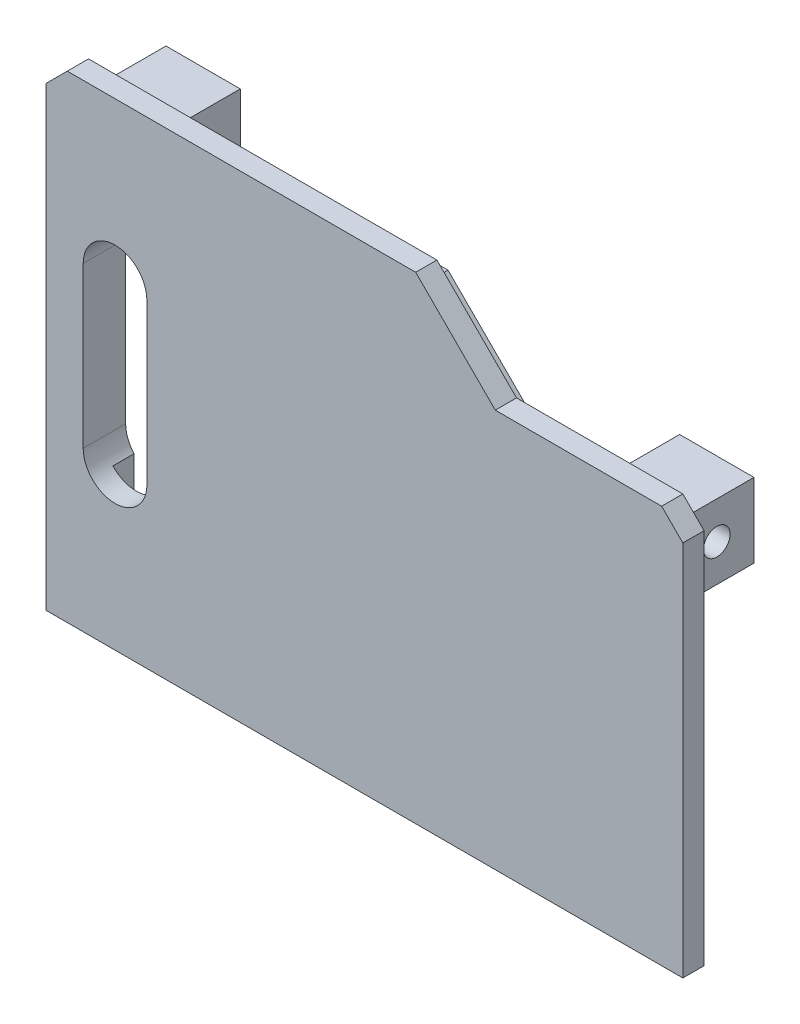
from build123d import *

# Parameters (mm, degrees)
EXTRUDE_1_DEPTH          = 2
EXTRUDE_3_DEPTH          = 2
SKETCH_5_W               = 7
SKETCH_5_H               = 7
SKETCH_5_R               = 1.25
EXTRUDE_4_DEPTH          = 7
SKETCH_6_W               = 7
SKETCH_6_H               = 7
SKETCH_6_R               = 1.25
EXTRUDE_5_DEPTH          = 7
CUT_EXTRUDE_1_DEPTH      = 7
CUT_EXTRUDE_1_DEPTH_BACK = 2


with BuildPart() as part:
    # Эскиз1 → Бобышка-Вытянуть1 (new body)
    with BuildSketch(Plane.XY):
        Polygon((-30, 20.5), (-28, 22.5), (4.828427125, 22.5), (12.328427125, 15), (28, 15), (30, 13), (30, -22.5), (-30, -22.5), align=None)
    extrude(amount=EXTRUDE_1_DEPTH)

    # Эскиз4 → Бобышка-Вытянуть3 (add)
    with BuildSketch(Plane(origin=(0, 0, 0), x_dir=(-1, 0, 0), z_dir=(0, 0, -1))):
        Polygon((-27.7, -20.2), (-27.7, 12.7), (-11.375735931, 12.7), (-3.875735931, 20.2), (27.7, 20.2), (27.7, -20.2), align=None)
        Polygon((-25.7, 10.7), (-10.547308807, 10.7), (-3.047308807, 18.2), (25.7, 18.2), (25.7, -18.2), (-25.7, -18.2), align=None, mode=Mode.SUBTRACT)
    extrude(amount=EXTRUDE_3_DEPTH)

    # Эскиз5 → Бобышка-Вытянуть4 (add)
    with BuildSketch(Plane(origin=(27.7, 0, 0), x_dir=(0, 0, -1), z_dir=(1, 0, 0))):
        with Locations((3.5, 9.2)):
            Rectangle(SKETCH_5_W, SKETCH_5_H)
        with Locations((3.5, 9.2)):
            Circle(SKETCH_5_R, mode=Mode.SUBTRACT)
    extrude(amount=-EXTRUDE_4_DEPTH)

    # Эскиз6 → Бобышка-Вытянуть5 (add)
    with BuildSketch(Plane.ZY.offset(27.7)):
        with Locations((-3.5, 16.7)):
            Rectangle(SKETCH_6_W, SKETCH_6_H)
        with Locations((-3.5, 16.7)):
            Circle(SKETCH_6_R, mode=Mode.SUBTRACT)
    extrude(amount=-EXTRUDE_5_DEPTH)

    # Эскиз7 → Вырез-Вытянуть1 (cut, two sides)
    with BuildSketch(Plane(origin=(0, 0, 0), x_dir=(-1, 0, 0), z_dir=(0, 0, -1))) as cut_extrude_1_sk:
        with BuildLine():
            Line((26.5, 7.555), (26.5, -7.525))
            ThreePointArc((26.5, -7.525), (23.5, -10.525), (20.5, -7.525))
            Line((20.5, -7.525), (20.5, 7.555))
            ThreePointArc((20.5, 7.555), (23.5, 10.555), (26.5, 7.555))
        make_face()
    extrude(amount=CUT_EXTRUDE_1_DEPTH, mode=Mode.SUBTRACT)
    extrude(cut_extrude_1_sk.sketch, amount=-CUT_EXTRUDE_1_DEPTH_BACK, mode=Mode.SUBTRACT)


solid = part.part
